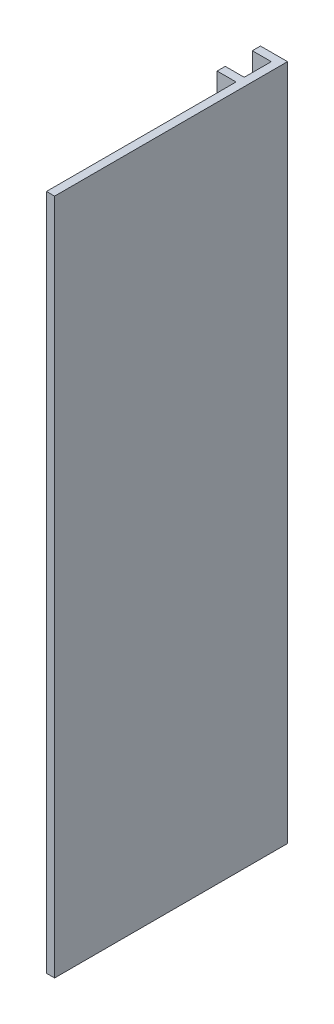
from build123d import *

# Parameters (mm, degrees)
BOSS_EXTRUDE1_DEPTH = 250


with BuildPart() as part:
    # Sketch2 → Boss-Extrude1 (new body)
    with BuildSketch(Plane(origin=(0, 0, 0), x_dir=(1, 0, 0), z_dir=(0, 1, 0))):
        Polygon((-1.133333333, 63.760867802), (8.866666667, 63.760867802), (8.866666667, -22.239132198), (5.866666667, -22.239132198), (5.866666667, 47.760867802), (-1.133333333, 47.760867802), (-1.133333333, 50.760867802), (5.866666667, 50.760867802), (5.866666667, 60.760867802), (-1.133333333, 60.760867802), align=None)
    extrude(amount=BOSS_EXTRUDE1_DEPTH)


solid = part.part
